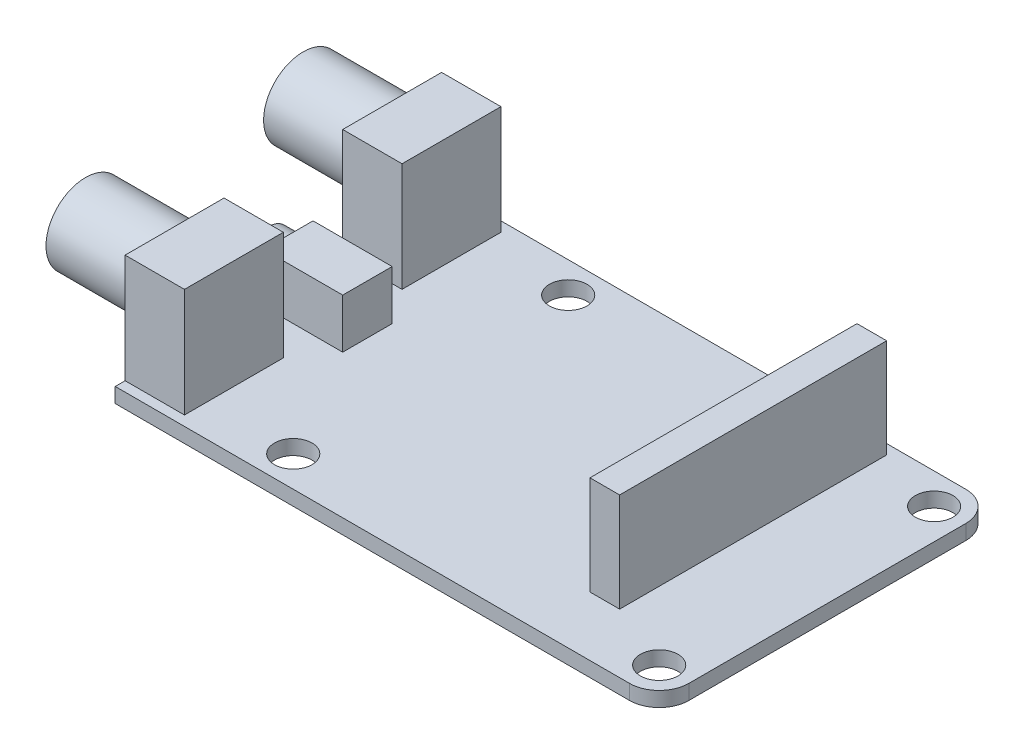
from build123d import *

# Parameters (mm, degrees)
SKETCH1_W           = 55
SKETCH1_H           = 34
BOSS_EXTRUDE1_DEPTH = 1.5
SKETCH2_R           = 1.9
CUT_EXTRUDE1_DEPTH  = 2.5
FILLET1_R           = 3
SKETCH3_W           = 8
SKETCH3_H           = 5
BOSS_EXTRUDE2_DEPTH = 5
SKETCH4_R           = 2.25
BOSS_EXTRUDE3_DEPTH = 2
SKETCH5_W           = 3
SKETCH5_H           = 27
BOSS_EXTRUDE4_DEPTH = 10
SKETCH6_W           = 6
SKETCH6_H           = 10
BOSS_EXTRUDE5_DEPTH = 11
SKETCH7_R           = 4
BOSS_EXTRUDE6_DEPTH = 9


with BuildPart() as part:
    # Sketch1 → Boss-Extrude1 (new body)
    with BuildSketch(Plane(origin=(0, 0, 0), x_dir=(1, 0, 0), z_dir=(0, 1, 0))):
        with Locations((27.5, -17)):
            Rectangle(SKETCH1_W, SKETCH1_H)
    extrude(amount=BOSS_EXTRUDE1_DEPTH)

    # Sketch2 → Cut-Extrude1 (cut, through all)
    with BuildSketch(Plane(origin=(0, 1.5, 0), x_dir=(1, 0, 0), z_dir=(0, 1, 0))):
        with Locations((51.9, -30.9)):
            Circle(SKETCH2_R)
        with Locations((14.9, -30.9)):
            Circle(SKETCH2_R)
        with Locations((14.9, -3.1)):
            Circle(SKETCH2_R)
        with Locations((51.9, -3.1)):
            Circle(SKETCH2_R)
    extrude(amount=-CUT_EXTRUDE1_DEPTH, mode=Mode.SUBTRACT)

    # Fillet1
    fillet1_edges = [part.edges().sort_by_distance(p)[0] for p in [
        (55, 0.75, 0),
        (55, 0.75, 34),
    ]]
    fillet(fillet1_edges, radius=FILLET1_R)

    # Sketch3 → Boss-Extrude2 (add)
    with BuildSketch(Plane(origin=(0, 1.5, 0), x_dir=(1, 0, 0), z_dir=(0, 1, 0))):
        with Locations((4.5, -17)):
            Rectangle(SKETCH3_W, SKETCH3_H)
    extrude(amount=BOSS_EXTRUDE2_DEPTH)

    # Sketch4 → Boss-Extrude3 (add)
    with BuildSketch(Plane.ZY.offset(-0.5)):
        with Locations((17, 4)):
            Circle(SKETCH4_R)
    extrude(amount=BOSS_EXTRUDE3_DEPTH)

    # Sketch5 → Boss-Extrude4 (add)
    with BuildSketch(Plane(origin=(0, 1.5, 0), x_dir=(1, 0, 0), z_dir=(0, 1, 0))):
        with Locations((43.5, -14.5)):
            Rectangle(SKETCH5_W, SKETCH5_H)
    extrude(amount=BOSS_EXTRUDE4_DEPTH)

    # Sketch6 → Boss-Extrude5 (add)
    with BuildSketch(Plane(origin=(0, 1.5, 0), x_dir=(1, 0, 0), z_dir=(0, 1, 0))):
        with Locations((3, -6)):
            Rectangle(SKETCH6_W, SKETCH6_H)
        with Locations((3, -28)):
            Rectangle(SKETCH6_W, SKETCH6_H)
    extrude(amount=BOSS_EXTRUDE5_DEPTH)

    # Sketch7 → Boss-Extrude6 (add)
    with BuildSketch(Plane.ZY):
        with Locations((28, 8.3)):
            Circle(SKETCH7_R)
        with Locations((6, 8.3)):
            Circle(SKETCH7_R)
    extrude(amount=BOSS_EXTRUDE6_DEPTH)


solid = part.part
